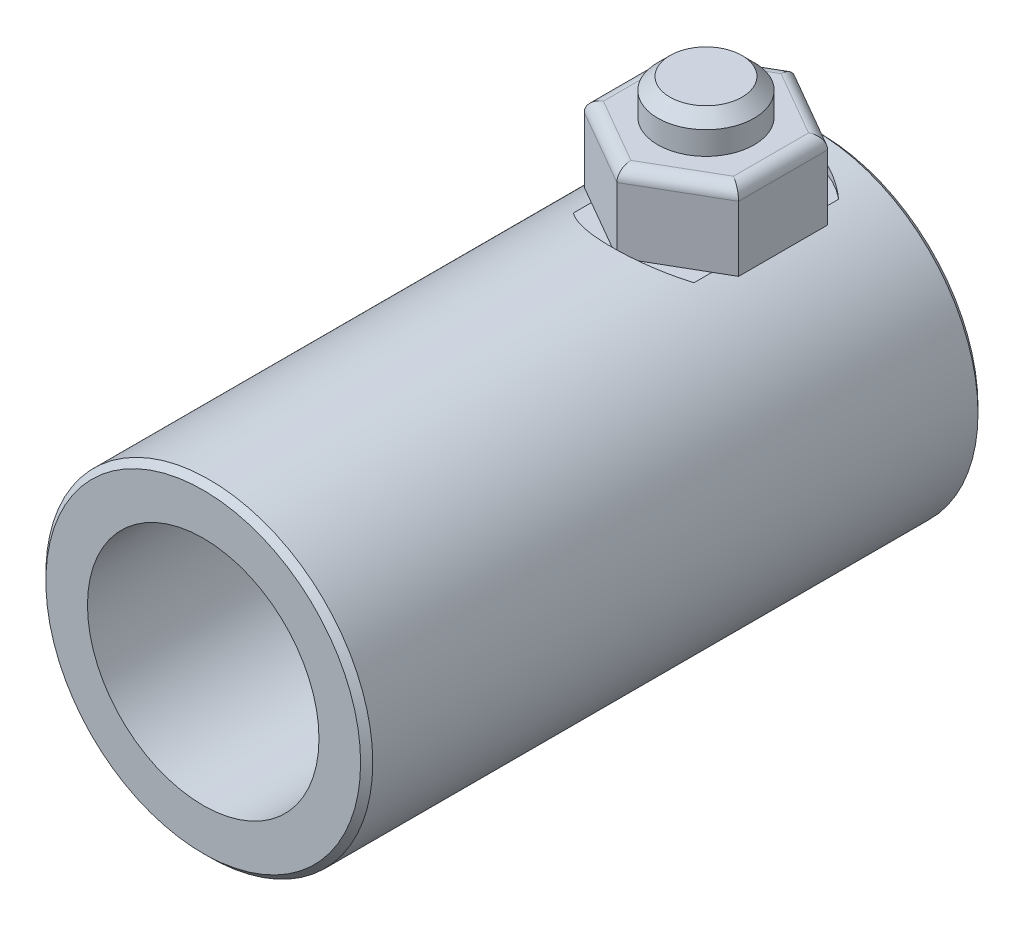
from build123d import *

# Parameters (mm, degrees)
BOSS_EXTRUDE1_DEPTH      = 25.4
BOSS_EXTRUDE1_DEPTH_BACK = 25.4
SKETCH1_R                = 13.45
SKETCH2_R                = 9.525
CUT_EXTRUDE1_DEPTH       = 25.4
SKETCH3_R                = 7.9375
CUT_EXTRUDE2_DEPTH       = 55.244308457
BOSS_EXTRUDE2_START      = 6.15
SKETCH4_R                = 3.96875
BOSS_EXTRUDE2_DEPTH      = 15.6
CUT_EXTRUDE4_START       = 12.5
SKETCH5_R                = 7.75
SKETCH5_R_2              = 3.96875
CUT_EXTRUDE4_DEPTH       = 24.543376814
BOSS_EXTRUDE3_DEPTH      = 6.35
FILLET1_R                = 1
CHAMFER1_SIZE            = 1
CHAMFER2_SIZE            = 0.5


with BuildPart() as part:
    # Sketch1 → Boss-Extrude1 (new, two sides: drawn at the far end of the back side and taken through both)
    with BuildSketch(Plane.XY.offset(-BOSS_EXTRUDE1_DEPTH_BACK)):
        Circle(SKETCH1_R)
    extrude(amount=BOSS_EXTRUDE1_DEPTH + BOSS_EXTRUDE1_DEPTH_BACK)

    # Sketch2 → Cut-Extrude1 (cut)
    with BuildSketch(Plane.XY.offset(25.4)):
        Circle(SKETCH2_R)
    extrude(amount=-CUT_EXTRUDE1_DEPTH, mode=Mode.SUBTRACT)

    # Sketch3 → Cut-Extrude2 (cut, through all)
    with BuildSketch(Plane(origin=(0, 0, -25.4), x_dir=(-1, 0, 0), z_dir=(0, 0, -1))):
        Circle(SKETCH3_R)
    extrude(amount=-CUT_EXTRUDE2_DEPTH, mode=Mode.SUBTRACT)

    # Sketch4 → Boss-Extrude2 (add)
    with BuildSketch(Plane(origin=(0, 0, 0), x_dir=(1, 0, 0), z_dir=(0, 1, 0)).offset(BOSS_EXTRUDE2_START)):
        with Locations((0, 15.96875)):
            Circle(SKETCH4_R)
    extrude(amount=BOSS_EXTRUDE2_DEPTH)

    # Sketch5 → Cut-Extrude4 (cut, through all)
    with BuildSketch(Plane(origin=(0, 0, 0), x_dir=(1, 0, 0), z_dir=(0, 1, 0)).offset(CUT_EXTRUDE4_START)):
        with Locations((0, 15.96875)):
            Circle(SKETCH5_R)
        with Locations((0, 15.96875)):
            Circle(SKETCH5_R_2, mode=Mode.SUBTRACT)
    extrude(amount=CUT_EXTRUDE4_DEPTH, mode=Mode.SUBTRACT)

    # Chamfer1
    chamfer1_edges = [part.edges().sort_by_distance(p)[0] for p in [
        (-3.96875, 21.75, -15.96875),
    ]]
    chamfer(chamfer1_edges, length=CHAMFER1_SIZE)

    # Chamfer2
    chamfer2_edges = [part.edges().sort_by_distance(p)[0] for p in [
        (-13.45, 0, -25.4),
        (-13.45, 0, 25.4),
    ]]
    chamfer(chamfer2_edges, length=CHAMFER2_SIZE)


with BuildPart() as body_2:
    # Sketch6 → Boss-Extrude3 (new body)
    with BuildSketch(Plane(origin=(0, 12.5, 0), x_dir=(1, 0, 0), z_dir=(0, 1, 0))):
        Polygon((6.35, 12.302575791), (6.35, 19.634924209), (0, 23.301098419), (-6.35, 19.634924209), (-6.35, 12.302575791), (0, 8.636401581), align=None)
    extrude(amount=BOSS_EXTRUDE3_DEPTH)

    # Fillet1
    fillet1_edges = [body_2.edges().sort_by_distance(p)[0] for p in [
        (-3.175, 18.85, -10.469488686),
        (-6.35, 18.85, -15.96875),
        (-3.175, 18.85, -21.468011314),
        (3.175, 18.85, -21.468011314),
        (6.35, 18.85, -15.96875),
        (3.175, 18.85, -10.469488686),
    ]]
    fillet(fillet1_edges, radius=FILLET1_R)


solid = Compound([part.part, body_2.part])
